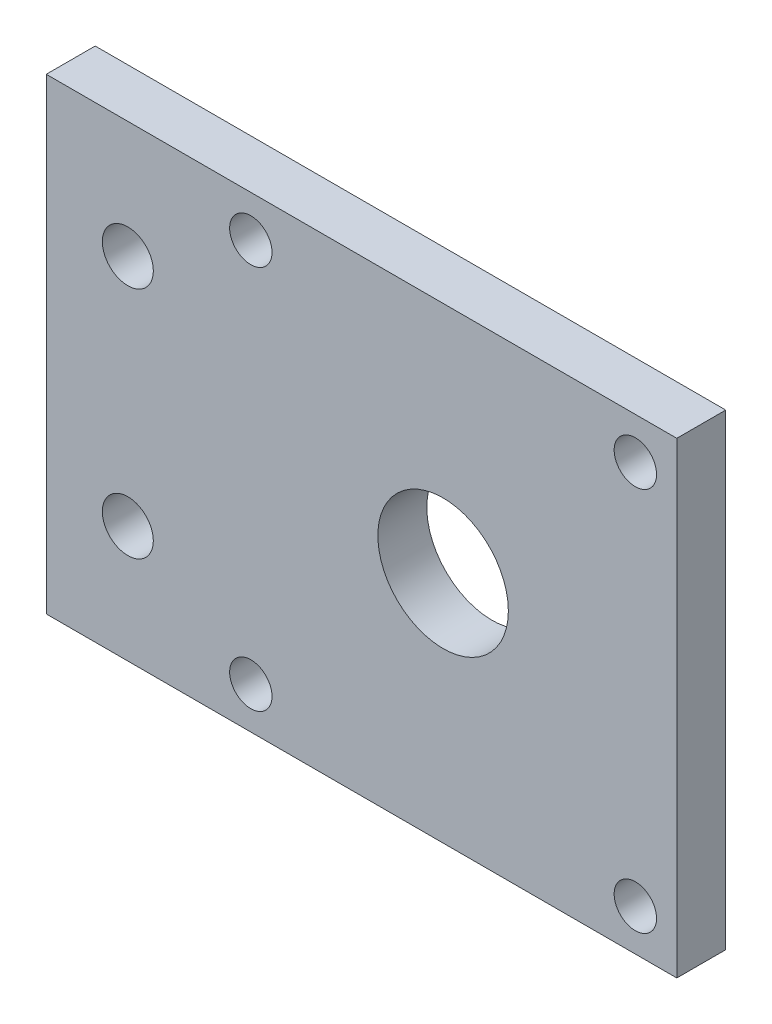
from build123d import *

# Parameters (mm, degrees)
SKETCH1_W                        = 77.3
SKETCH1_H                        = 57.3
BOSS_EXTRUDE1_DEPTH              = 6
SKETCH2_R                        = 8
SKETCH2_R_2                      = 2.6
CUT_EXTRUDE1_DEPTH               = 6
TAP_DRILL_FOR_M6_HELICOIL1_D     = 6.25
TAP_DRILL_FOR_M6_HELICOIL1_DEPTH = 20
TAP_DRILL_FOR_M6_HELICOIL1_TIP   = 1.877689434


with BuildPart() as part:
    # Sketch1 → Boss-Extrude1 (new body)
    with BuildSketch(Plane.XY):
        Rectangle(SKETCH1_W, SKETCH1_H)
    extrude(amount=BOSS_EXTRUDE1_DEPTH)

    # Sketch2 → Cut-Extrude1 (cut)
    with BuildSketch(Plane.XY.offset(6)):
        with Locations((10, 0)):
            Circle(SKETCH2_R)
        with Locations((-13.57, 23.57)):
            Circle(SKETCH2_R_2)
        with Locations((33.57, 23.57)):
            Circle(SKETCH2_R_2)
        with Locations((33.57, -23.57)):
            Circle(SKETCH2_R_2)
        with Locations((-13.57, -23.57)):
            Circle(SKETCH2_R_2)
    extrude(amount=-CUT_EXTRUDE1_DEPTH, mode=Mode.SUBTRACT)

    # Tap Drill for M6 Helicoil1
    with Locations(Plane(origin=(-28.65, 14.325, 6), x_dir=(1, 0, 0), z_dir=(0, 0, 1))):
        with Locations((0, 0), (0, -28.65)):
            Hole(TAP_DRILL_FOR_M6_HELICOIL1_D / 2, depth=TAP_DRILL_FOR_M6_HELICOIL1_DEPTH)
            with Locations((0, 0, -(TAP_DRILL_FOR_M6_HELICOIL1_DEPTH + TAP_DRILL_FOR_M6_HELICOIL1_TIP / 2))):  # 118° drill point
                Cone(0, TAP_DRILL_FOR_M6_HELICOIL1_D / 2, TAP_DRILL_FOR_M6_HELICOIL1_TIP, mode=Mode.SUBTRACT)


solid = part.part
